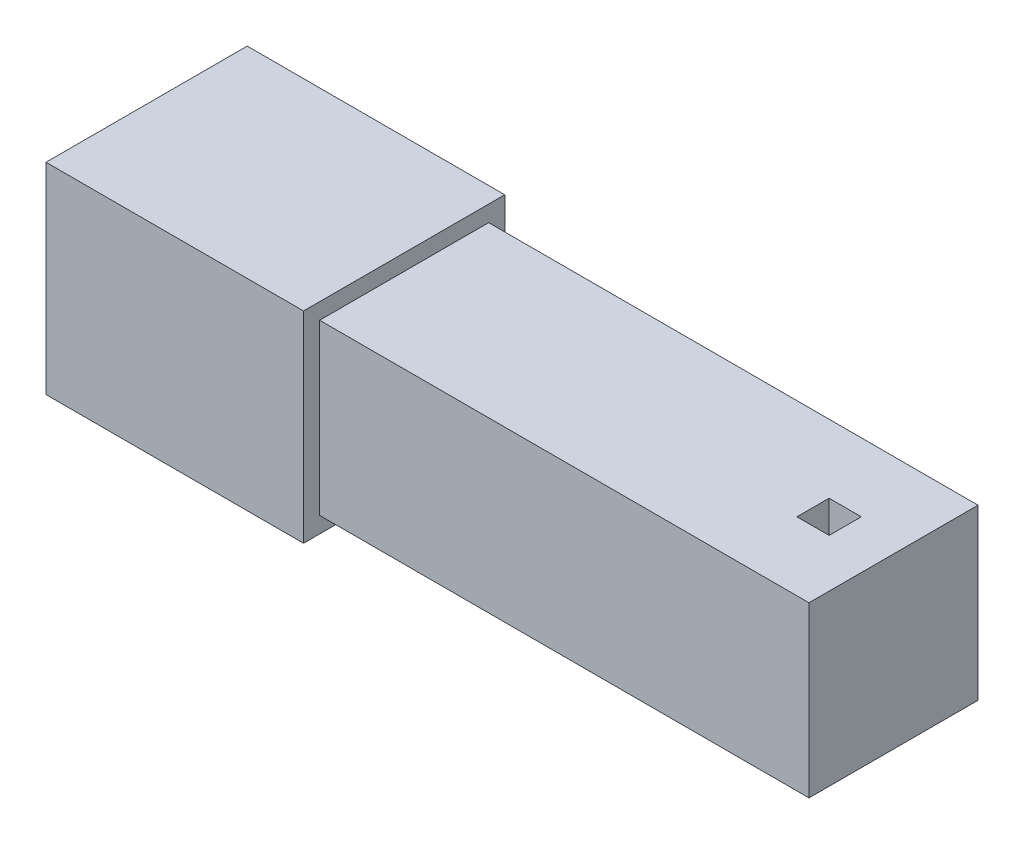
from build123d import *

# Parameters (mm, degrees)
SKETCH1_W           = 105
SKETCH1_H           = 105
BOSS_EXTRUDE1_DEPTH = 304
SKETCH2_W           = 20
SKETCH2_H           = 20
BOSS_EXTRUDE2_DEPTH = 152
SKETCH3_W           = 125
SKETCH3_H           = 125
SKETCH3_W_2         = 105
SKETCH3_H_2         = 105
EXTRUDE_THIN1_DEPTH = 160
SKETCH4_W           = 20
SKETCH4_H           = 20
CUT_EXTRUDE1_DEPTH  = 160


with BuildPart() as part:
    # Sketch1 → Boss-Extrude1 (new body)
    with BuildSketch(Plane(origin=(0, 0, 0), x_dir=(0, 0, -1), z_dir=(1, 0, 0))):
        Rectangle(SKETCH1_W, SKETCH1_H)
    extrude(amount=BOSS_EXTRUDE1_DEPTH)

    # Sketch2 → Boss-Extrude2 (add)
    with BuildSketch(Plane.ZY):
        Rectangle(SKETCH2_W, SKETCH2_H)
    extrude(amount=BOSS_EXTRUDE2_DEPTH)

    # Sketch4 → Cut-Extrude1 (cut)
    with BuildSketch(Plane.XZ.offset(52.5)):
        with Locations((264, 0)):
            Rectangle(SKETCH4_W, SKETCH4_H)
    extrude(amount=-CUT_EXTRUDE1_DEPTH, mode=Mode.SUBTRACT)


with BuildPart() as body_2:
    # Sketch3 → Extrude-Thin1 (new body)
    with BuildSketch(Plane.ZY):
        Rectangle(SKETCH3_W, SKETCH3_H)
        Rectangle(SKETCH3_W_2, SKETCH3_H_2, mode=Mode.SUBTRACT)
    extrude(amount=EXTRUDE_THIN1_DEPTH)


solid = Compound([part.part, body_2.part])
